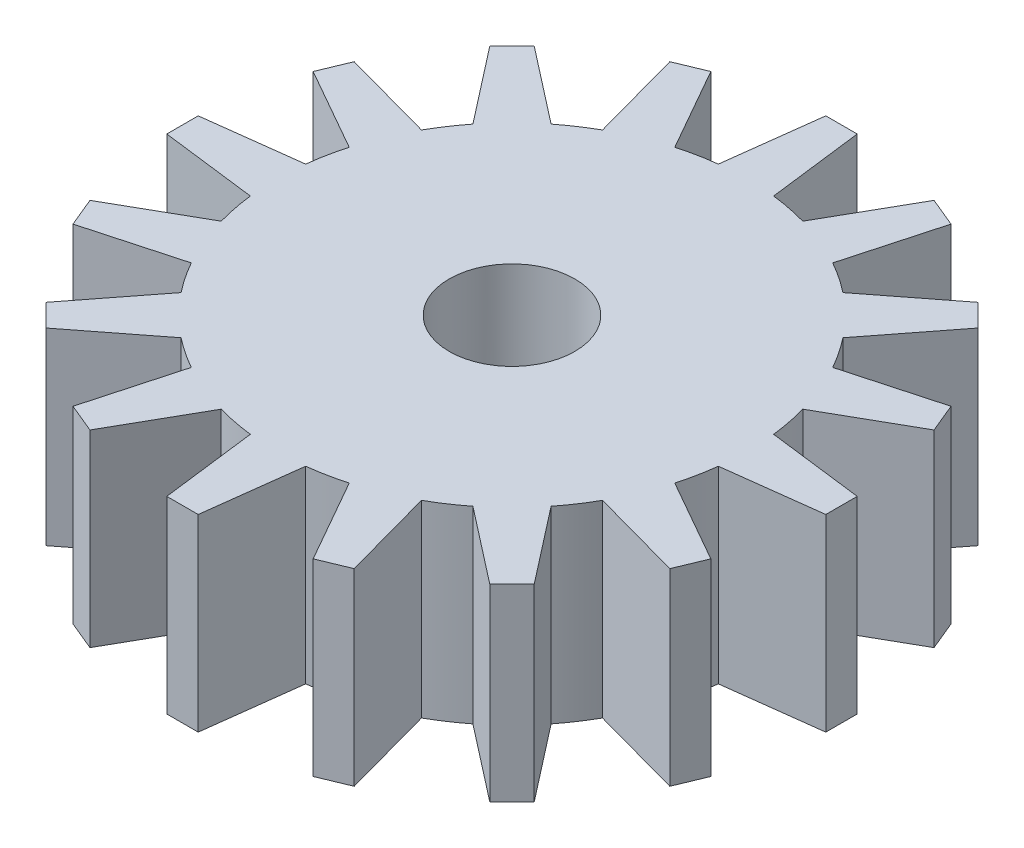
from build123d import *

# Parameters (mm, degrees)
SKICA1_R                 = 3.75
P_IDAT_VYSUNUT_M1_DEPTH  = 3
P_IDAT_VYSUNUT_M2_DEPTH  = 3
KRUHOV_POLE1_COUNT       = 16
SKICA3_R                 = 1
ODEBRAT_VYSUNUT_M1_DEPTH = 5
SKICA4_R                 = 2.5
ODEBRAT_VYSUNUT_M2_DEPTH = 1.5


with BuildPart() as part:
    # Skica1 → Přidat vysunutím1 (new body)
    with BuildSketch(Plane(origin=(0, 0, 0), x_dir=(1, 0, 0), z_dir=(0, 1, 0))):
        Circle(SKICA1_R)
    extrude(amount=P_IDAT_VYSUNUT_M1_DEPTH)

    # Skica2 → Přidat vysunutím2 (add)
    with BuildSketch(Plane(origin=(0, 3, 0), x_dir=(1, 0, 0), z_dir=(0, 1, 0))):
        with BuildLine():
            Line((0, 5.244044241), (0.25, 5.244044241))
            Line((0.25, 5.244044241), (0.439992833, 3.724098053))
            ThreePointArc((0.439992833, 3.724098053), (0, 3.75), (-0.439992833, 3.724098053))
            Line((-0.439992833, 3.724098053), (-0.25, 5.244044241))
            Line((-0.25, 5.244044241), (0, 5.244044241))
        make_face()
    p_idat_vysunut_m2 = extrude(amount=-P_IDAT_VYSUNUT_M2_DEPTH)

    # Kruhové pole1: Přidat vysunutím2 ×16 about axis
    kruhov_pole1_axis = Axis((0, 0, 0), (0, 1, 0))
    for i in range(1, KRUHOV_POLE1_COUNT):
        add(p_idat_vysunut_m2.rotate(kruhov_pole1_axis, i * 360 / KRUHOV_POLE1_COUNT))

    # Skica3 → Odebrat vysunutím1 (cut)
    with BuildSketch(Plane.XZ):
        Circle(SKICA3_R)
    extrude(amount=-ODEBRAT_VYSUNUT_M1_DEPTH, mode=Mode.SUBTRACT)

    # Skica4 → Odebrat vysunutím2 (cut)
    with BuildSketch(Plane.XZ):
        Circle(SKICA4_R)
    extrude(amount=-ODEBRAT_VYSUNUT_M2_DEPTH, mode=Mode.SUBTRACT)


solid = part.part
